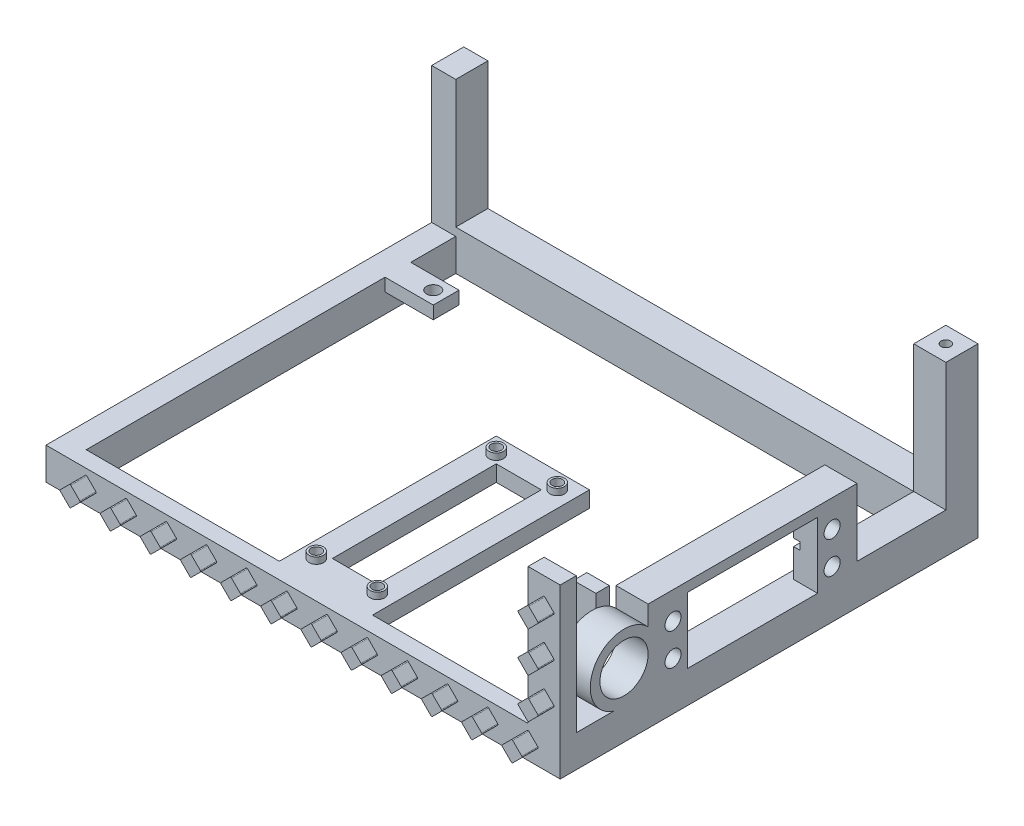
from build123d import *

# Parameters (mm, degrees)
SKETCH1_W            = 160
SKETCH1_H            = 130
BOSS_EXTRUDE1_DEPTH  = 10
BOSS_EXTRUDE2_DEPTH  = 42.3
BOSS_EXTRUDE3_DEPTH  = 5
SKETCH7_R            = 2.1
CUT_EXTRUDE2_DEPTH   = 118.958848757
CUT_EXTRUDE3_DEPTH   = 118.958848757
SKETCH11_R           = 1.5
CUT_EXTRUDE6_DEPTH   = 4
SKETCH12_W           = 142.5
SKETCH12_H           = 39.8
CUT_EXTRUDE7_DEPTH   = 160.954024645
SKETCH15_W           = 29
SKETCH15_H           = 67.5
SKETCH15_W_2         = 14
SKETCH15_H_2         = 51
SKETCH15_R           = 1.625
BOSS_EXTRUDE4_DEPTH  = 5
BOSS_EXTRUDE5_START  = 2
SKETCH15_4_R         = 2.25
SKETCH15_4_R_2       = 1.625
BOSS_EXTRUDE5_DEPTH  = 2
CUT_EXTRUDE20_DEPTH  = 5.25
SKETCH26_W           = 15
SKETCH26_H           = 8
CUT_EXTRUDE21_DEPTH  = 6
SKETCH36_W           = 55
SKETCH36_H           = 20.5
CUT_EXTRUDE27_DEPTH  = 2.5
SKETCH37_W           = 7.25
SKETCH37_H           = 2.3
CUT_EXTRUDE28_DEPTH  = 2
CUT_EXTRUDE30_DEPTH  = 10
SKETCH40_R           = 7.5
CUT_EXTRUDE32_DEPTH  = 10
SKETCH38_R           = 2.5
CUT_EXTRUDE33_DEPTH  = 10
SKETCH41_W           = 40.5
SKETCH41_H           = 20.5
CUT_EXTRUDE34_DEPTH  = 10
SKETCH48_W           = 4.2
SKETCH48_H           = 3
BOSS_EXTRUDE9_DEPTH  = 21.5
SKETCH49_W           = 7
SKETCH49_H           = 4.2
BOSS_EXTRUDE10_DEPTH = 10


with BuildPart() as part:
    # Sketch1 → Boss-Extrude1 (new body)
    with BuildSketch(Plane(origin=(0, 0, 0), x_dir=(1, 0, 0), z_dir=(0, 1, 0))):
        with Locations((-5, 5)):
            Rectangle(SKETCH1_W, SKETCH1_H)
    extrude(amount=BOSS_EXTRUDE1_DEPTH)

    # Sketch2 → Boss-Extrude2 (add)
    with BuildSketch(Plane(origin=(0, 10, 0), x_dir=(1, 0, 0), z_dir=(0, 1, 0))):
        Polygon((-85, 70), (75, 70), (75, -60), (65, -60), (65, 60), (-85, 60), align=None)
    extrude(amount=BOSS_EXTRUDE2_DEPTH)

    # Sketch6 → Boss-Extrude3 (add)
    with BuildSketch(Plane.XY.offset(60)):
        with BuildLine():
            Line((69.787867966, 40.612132034), (66.962132034, 43.437867966))
            ThreePointArc((66.962132034, 43.437867966), (66.874264069, 43.65), (66.962132034, 43.862132034))
            Line((66.962132034, 43.862132034), (69.787867966, 46.687867966))
            ThreePointArc((69.787867966, 46.687867966), (70, 46.775735931), (70.212132034, 46.687867966))
            Line((70.212132034, 46.687867966), (73.037867966, 43.862132034))
            ThreePointArc((73.037867966, 43.862132034), (73.125735931, 43.65), (73.037867966, 43.437867966))
            Line((73.037867966, 43.437867966), (70.212132034, 40.612132034))
            ThreePointArc((70.212132034, 40.612132034), (70, 40.524264069), (69.787867966, 40.612132034))
        make_face()
        with BuildLine():
            Line((-10.212132034, 8.037867966), (-13.037867966, 5.212132034))
            ThreePointArc((-13.037867966, 5.212132034), (-13.125735931, 5), (-13.037867966, 4.787867966))
            Line((-13.037867966, 4.787867966), (-10.212132034, 1.962132034))
            ThreePointArc((-10.212132034, 1.962132034), (-10, 1.874264069), (-9.787867966, 1.962132034))
            Line((-9.787867966, 1.962132034), (-6.962132034, 4.787867966))
            ThreePointArc((-6.962132034, 4.787867966), (-6.874264069, 5), (-6.962132034, 5.212132034))
            Line((-6.962132034, 5.212132034), (-9.787867966, 8.037867966))
            ThreePointArc((-9.787867966, 8.037867966), (-10, 8.125735931), (-10.212132034, 8.037867966))
        make_face()
        with BuildLine():
            Line((66.962132034, 31.362132034), (69.787867966, 34.187867966))
            ThreePointArc((69.787867966, 34.187867966), (70, 34.275735931), (70.212132034, 34.187867966))
            Line((70.212132034, 34.187867966), (73.037867966, 31.362132034))
            ThreePointArc((73.037867966, 31.362132034), (73.125735931, 31.15), (73.037867966, 30.937867966))
            Line((73.037867966, 30.937867966), (70.212132034, 28.112132034))
            ThreePointArc((70.212132034, 28.112132034), (70, 28.024264069), (69.787867966, 28.112132034))
            Line((69.787867966, 28.112132034), (66.962132034, 30.937867966))
            ThreePointArc((66.962132034, 30.937867966), (66.874264069, 31.15), (66.962132034, 31.362132034))
        make_face()
        with BuildLine():
            Line((5.537867966, 5.212132034), (2.712132034, 8.037867966))
            ThreePointArc((2.712132034, 8.037867966), (2.5, 8.125735931), (2.287867966, 8.037867966))
            Line((2.287867966, 8.037867966), (-0.537867966, 5.212132034))
            ThreePointArc((-0.537867966, 5.212132034), (-0.625735931, 5), (-0.537867966, 4.787867966))
            Line((-0.537867966, 4.787867966), (2.287867966, 1.962132034))
            ThreePointArc((2.287867966, 1.962132034), (2.5, 1.874264069), (2.712132034, 1.962132034))
            Line((2.712132034, 1.962132034), (5.537867966, 4.787867966))
            ThreePointArc((5.537867966, 4.787867966), (5.625735931, 5), (5.537867966, 5.212132034))
        make_face()
        with BuildLine():
            Line((18.037867966, 5.212132034), (15.212132034, 8.037867966))
            ThreePointArc((15.212132034, 8.037867966), (15, 8.125735931), (14.787867966, 8.037867966))
            Line((14.787867966, 8.037867966), (11.962132034, 5.212132034))
            ThreePointArc((11.962132034, 5.212132034), (11.874264069, 5), (11.962132034, 4.787867966))
            Line((11.962132034, 4.787867966), (14.787867966, 1.962132034))
            ThreePointArc((14.787867966, 1.962132034), (15, 1.874264069), (15.212132034, 1.962132034))
            Line((15.212132034, 1.962132034), (18.037867966, 4.787867966))
            ThreePointArc((18.037867966, 4.787867966), (18.125735931, 5), (18.037867966, 5.212132034))
        make_face()
        with BuildLine():
            Line((30.537867966, 5.212132034), (27.712132034, 8.037867966))
            ThreePointArc((27.712132034, 8.037867966), (27.5, 8.125735931), (27.287867966, 8.037867966))
            Line((27.287867966, 8.037867966), (24.462132034, 5.212132034))
            ThreePointArc((24.462132034, 5.212132034), (24.374264069, 5), (24.462132034, 4.787867966))
            Line((24.462132034, 4.787867966), (27.287867966, 1.962132034))
            ThreePointArc((27.287867966, 1.962132034), (27.5, 1.874264069), (27.712132034, 1.962132034))
            Line((27.712132034, 1.962132034), (30.537867966, 4.787867966))
            ThreePointArc((30.537867966, 4.787867966), (30.625735931, 5), (30.537867966, 5.212132034))
        make_face()
        with BuildLine():
            Line((43.037867966, 5.212132034), (40.212132034, 8.037867966))
            ThreePointArc((40.212132034, 8.037867966), (40, 8.125735931), (39.787867966, 8.037867966))
            Line((39.787867966, 8.037867966), (36.962132034, 5.212132034))
            ThreePointArc((36.962132034, 5.212132034), (36.874264069, 5), (36.962132034, 4.787867966))
            Line((36.962132034, 4.787867966), (39.787867966, 1.962132034))
            ThreePointArc((39.787867966, 1.962132034), (40, 1.874264069), (40.212132034, 1.962132034))
            Line((40.212132034, 1.962132034), (43.037867966, 4.787867966))
            ThreePointArc((43.037867966, 4.787867966), (43.125735931, 5), (43.037867966, 5.212132034))
        make_face()
        with BuildLine():
            Line((55.537867966, 5.212132034), (52.712132034, 8.037867966))
            ThreePointArc((52.712132034, 8.037867966), (52.5, 8.125735931), (52.287867966, 8.037867966))
            Line((52.287867966, 8.037867966), (49.462132034, 5.212132034))
            ThreePointArc((49.462132034, 5.212132034), (49.374264069, 5), (49.462132034, 4.787867966))
            Line((49.462132034, 4.787867966), (52.287867966, 1.962132034))
            ThreePointArc((52.287867966, 1.962132034), (52.5, 1.874264069), (52.712132034, 1.962132034))
            Line((52.712132034, 1.962132034), (55.537867966, 4.787867966))
            ThreePointArc((55.537867966, 4.787867966), (55.625735931, 5), (55.537867966, 5.212132034))
        make_face()
        with BuildLine():
            Line((68.037867966, 5.212132034), (65.212132034, 8.037867966))
            ThreePointArc((65.212132034, 8.037867966), (65, 8.125735931), (64.787867966, 8.037867966))
            Line((64.787867966, 8.037867966), (61.962132034, 5.212132034))
            ThreePointArc((61.962132034, 5.212132034), (61.874264069, 5), (61.962132034, 4.787867966))
            Line((61.962132034, 4.787867966), (64.787867966, 1.962132034))
            ThreePointArc((64.787867966, 1.962132034), (65, 1.874264069), (65.212132034, 1.962132034))
            Line((65.212132034, 1.962132034), (68.037867966, 4.787867966))
            ThreePointArc((68.037867966, 4.787867966), (68.125735931, 5), (68.037867966, 5.212132034))
        make_face()
        with BuildLine():
            Line((-19.462132034, 5.212132034), (-22.287867966, 8.037867966))
            ThreePointArc((-22.287867966, 8.037867966), (-22.5, 8.125735931), (-22.712132034, 8.037867966))
            Line((-22.712132034, 8.037867966), (-25.537867966, 5.212132034))
            ThreePointArc((-25.537867966, 5.212132034), (-25.625735931, 5), (-25.537867966, 4.787867966))
            Line((-25.537867966, 4.787867966), (-22.712132034, 1.962132034))
            ThreePointArc((-22.712132034, 1.962132034), (-22.5, 1.874264069), (-22.287867966, 1.962132034))
            Line((-22.287867966, 1.962132034), (-19.462132034, 4.787867966))
            ThreePointArc((-19.462132034, 4.787867966), (-19.374264069, 5), (-19.462132034, 5.212132034))
        make_face()
        with BuildLine():
            Line((-31.962132034, 5.212132034), (-34.787867966, 8.037867966))
            ThreePointArc((-34.787867966, 8.037867966), (-35, 8.125735931), (-35.212132034, 8.037867966))
            Line((-35.212132034, 8.037867966), (-38.037867966, 5.212132034))
            ThreePointArc((-38.037867966, 5.212132034), (-38.125735931, 5), (-38.037867966, 4.787867966))
            Line((-38.037867966, 4.787867966), (-35.212132034, 1.962132034))
            ThreePointArc((-35.212132034, 1.962132034), (-35, 1.874264069), (-34.787867966, 1.962132034))
            Line((-34.787867966, 1.962132034), (-31.962132034, 4.787867966))
            ThreePointArc((-31.962132034, 4.787867966), (-31.874264069, 5), (-31.962132034, 5.212132034))
        make_face()
        with BuildLine():
            Line((-44.462132034, 5.212132034), (-47.287867966, 8.037867966))
            ThreePointArc((-47.287867966, 8.037867966), (-47.5, 8.125735931), (-47.712132034, 8.037867966))
            Line((-47.712132034, 8.037867966), (-50.537867966, 5.212132034))
            ThreePointArc((-50.537867966, 5.212132034), (-50.625735931, 5), (-50.537867966, 4.787867966))
            Line((-50.537867966, 4.787867966), (-47.712132034, 1.962132034))
            ThreePointArc((-47.712132034, 1.962132034), (-47.5, 1.874264069), (-47.287867966, 1.962132034))
            Line((-47.287867966, 1.962132034), (-44.462132034, 4.787867966))
            ThreePointArc((-44.462132034, 4.787867966), (-44.374264069, 5), (-44.462132034, 5.212132034))
        make_face()
        with BuildLine():
            Line((-56.962132034, 5.212132034), (-59.787867966, 8.037867966))
            ThreePointArc((-59.787867966, 8.037867966), (-60, 8.125735931), (-60.212132034, 8.037867966))
            Line((-60.212132034, 8.037867966), (-63.037867966, 5.212132034))
            ThreePointArc((-63.037867966, 5.212132034), (-63.125735931, 5), (-63.037867966, 4.787867966))
            Line((-63.037867966, 4.787867966), (-60.212132034, 1.962132034))
            ThreePointArc((-60.212132034, 1.962132034), (-60, 1.874264069), (-59.787867966, 1.962132034))
            Line((-59.787867966, 1.962132034), (-56.962132034, 4.787867966))
            ThreePointArc((-56.962132034, 4.787867966), (-56.874264069, 5), (-56.962132034, 5.212132034))
        make_face()
        with BuildLine():
            Line((-69.462132034, 5.212132034), (-72.287867966, 8.037867966))
            ThreePointArc((-72.287867966, 8.037867966), (-72.5, 8.125735931), (-72.712132034, 8.037867966))
            Line((-72.712132034, 8.037867966), (-75.537867966, 5.212132034))
            ThreePointArc((-75.537867966, 5.212132034), (-75.625735931, 5), (-75.537867966, 4.787867966))
            Line((-75.537867966, 4.787867966), (-72.712132034, 1.962132034))
            ThreePointArc((-72.712132034, 1.962132034), (-72.5, 1.874264069), (-72.287867966, 1.962132034))
            Line((-72.287867966, 1.962132034), (-69.462132034, 4.787867966))
            ThreePointArc((-69.462132034, 4.787867966), (-69.374264069, 5), (-69.462132034, 5.212132034))
        make_face()
        with BuildLine():
            Line((69.787867966, 15.612132034), (66.962132034, 18.437867966))
            ThreePointArc((66.962132034, 18.437867966), (66.874264069, 18.65), (66.962132034, 18.862132034))
            Line((66.962132034, 18.862132034), (69.787867966, 21.687867966))
            ThreePointArc((69.787867966, 21.687867966), (70, 21.775735931), (70.212132034, 21.687867966))
            Line((70.212132034, 21.687867966), (73.037867966, 18.862132034))
            ThreePointArc((73.037867966, 18.862132034), (73.125735931, 18.65), (73.037867966, 18.437867966))
            Line((73.037867966, 18.437867966), (70.212132034, 15.612132034))
            ThreePointArc((70.212132034, 15.612132034), (70, 15.524264069), (69.787867966, 15.612132034))
        make_face()
    extrude(amount=BOSS_EXTRUDE3_DEPTH)

    # Sketch7 → Cut-Extrude2 (cut, through all)
    with BuildSketch(Plane(origin=(0, 10, 0), x_dir=(1, 0, 0), z_dir=(0, 1, 0))):
        with Locations((-66.5, 42)):
            Circle(SKETCH7_R)
    extrude(amount=-CUT_EXTRUDE2_DEPTH, mode=Mode.SUBTRACT)

    # Sketch8 → Cut-Extrude3 (cut, through all)
    with BuildSketch(Plane(origin=(0, 10, 0), x_dir=(1, 0, 0), z_dir=(0, 1, 0))):
        Polygon((-77.5, 60), (65, 60), (65, -55), (-77.5, -55), (-77.5, 38), (-62.5, 38), (-62.5, 46), (-77.5, 46), align=None)
    extrude(amount=-CUT_EXTRUDE3_DEPTH, mode=Mode.SUBTRACT)

    # Sketch11 → Cut-Extrude6 (cut)
    with BuildSketch(Plane(origin=(0, 52.3, 0), x_dir=(1, 0, 0), z_dir=(0, 1, 0))):
        with Locations((70, 65)):
            Circle(SKETCH11_R)
    extrude(amount=-CUT_EXTRUDE6_DEPTH, mode=Mode.SUBTRACT)

    # Sketch12 → Cut-Extrude7 (cut, through all)
    with BuildSketch(Plane.XY.offset(-60)):
        with Locations((-6.25, 32.4)):
            Rectangle(SKETCH12_W, SKETCH12_H)
    extrude(amount=-CUT_EXTRUDE7_DEPTH, mode=Mode.SUBTRACT)

    # Sketch15 → Boss-Extrude4 (add)
    with BuildSketch(Plane(origin=(0, 10, 0), x_dir=(1, 0, 0), z_dir=(0, 1, 0))):
        with Locations((-2.9, -21.25)):
            Rectangle(SKETCH15_W, SKETCH15_H)
        with Locations((-2.9, -20.5)):
            Rectangle(SKETCH15_W_2, SKETCH15_H_2, mode=Mode.SUBTRACT)
        with Locations((-12.4, -48.5)):
            Circle(SKETCH15_R, mode=Mode.SUBTRACT)
        with Locations((6.6, -48.5)):
            Circle(SKETCH15_R, mode=Mode.SUBTRACT)
        with Locations((-12.4, 7.5)):
            Circle(SKETCH15_R, mode=Mode.SUBTRACT)
        with Locations((6.6, 7.5)):
            Circle(SKETCH15_R, mode=Mode.SUBTRACT)
    extrude(amount=-BOSS_EXTRUDE4_DEPTH)

    # Sketch15_4 → Boss-Extrude5 (add)
    # profile 1 of 4: a face of its own
    with BuildSketch(Plane(origin=(0, 10, 0), x_dir=(1, 0, 0), z_dir=(0, 1, 0)).offset(BOSS_EXTRUDE5_START)):
        with Locations((-12.4, 7.5)):
            Circle(SKETCH15_4_R)
        with Locations((-12.4, 7.5)):
            Circle(SKETCH15_4_R_2, mode=Mode.SUBTRACT)
    # profile 2 of 4: a face of its own
    with BuildSketch(Plane(origin=(0, 10, 0), x_dir=(1, 0, 0), z_dir=(0, 1, 0)).offset(BOSS_EXTRUDE5_START)):
        with Locations((6.6, 7.5)):
            Circle(SKETCH15_4_R)
        with Locations((6.6, 7.5)):
            Circle(SKETCH15_4_R_2, mode=Mode.SUBTRACT)
    # profile 3 of 4: a face of its own
    with BuildSketch(Plane(origin=(0, 10, 0), x_dir=(1, 0, 0), z_dir=(0, 1, 0)).offset(BOSS_EXTRUDE5_START)):
        with Locations((-12.4, -48.5)):
            Circle(SKETCH15_4_R)
        with Locations((-12.4, -48.5)):
            Circle(SKETCH15_4_R_2, mode=Mode.SUBTRACT)
    # profile 4 of 4: a face of its own
    with BuildSketch(Plane(origin=(0, 10, 0), x_dir=(1, 0, 0), z_dir=(0, 1, 0)).offset(BOSS_EXTRUDE5_START)):
        with Locations((6.6, -48.5)):
            Circle(SKETCH15_4_R)
        with Locations((6.6, -48.5)):
            Circle(SKETCH15_4_R_2, mode=Mode.SUBTRACT)
    extrude(amount=-BOSS_EXTRUDE5_DEPTH)

    # Sketch25 → Cut-Extrude20 (cut)
    with BuildSketch(Plane.ZY.offset(85)):
        Polygon((0, 8.425), (-3.425, 5), (0, 1.575), (3.425, 5), align=None)
        Polygon((15.925, 5), (12.5, 8.425), (9.075, 5), (12.5, 1.575), align=None)
        Polygon((28.425, 5), (25, 8.425), (21.575, 5), (25, 1.575), align=None)
        Polygon((40.925, 5), (37.5, 8.425), (34.075, 5), (37.5, 1.575), align=None)
        Polygon((53.425, 5), (50, 8.425), (46.575, 5), (50, 1.575), align=None)
        Polygon((-9.075, 5), (-12.5, 8.425), (-15.925, 5), (-12.5, 1.575), align=None)
        Polygon((-21.575, 5), (-25, 8.425), (-28.425, 5), (-25, 1.575), align=None)
        Polygon((-34.075, 5), (-37.5, 8.425), (-40.925, 5), (-37.5, 1.575), align=None)
        Polygon((-46.575, 5), (-50, 8.425), (-53.425, 5), (-50, 1.575), align=None)
        Polygon((-59.075, 5), (-62.5, 8.425), (-65.925, 5), (-62.5, 1.575), align=None)
        Polygon((-68.425, 31.15), (-65, 34.575), (-61.575, 31.15), (-65, 27.725), align=None)
        Polygon((-65, 15.225), (-68.425, 18.65), (-65, 22.075), (-61.575, 18.65), align=None)
        Polygon((-65, 40.225), (-68.425, 43.65), (-65, 47.075), (-61.575, 43.65), align=None)
    extrude(amount=-CUT_EXTRUDE20_DEPTH, mode=Mode.SUBTRACT)

    # Sketch26 → Cut-Extrude21 (cut)
    with BuildSketch(Plane.XZ):
        with Locations((-70, -42)):
            Rectangle(SKETCH26_W, SKETCH26_H)
    extrude(amount=-CUT_EXTRUDE21_DEPTH, mode=Mode.SUBTRACT)

    # Sketch36 → Cut-Extrude27 (cut)
    with BuildSketch(Plane.ZY.offset(-65)):
        with Locations((0.15, 20.25)):
            Rectangle(SKETCH36_W, SKETCH36_H)
    extrude(amount=-CUT_EXTRUDE27_DEPTH, mode=Mode.SUBTRACT)

    # Sketch37 → Cut-Extrude28 (cut)
    with BuildSketch(Plane.ZY.offset(-67.5)):
        with Locations((-23.725, 20)):
            Rectangle(SKETCH37_W, SKETCH37_H)
    cut_extrude28 = extrude(amount=-CUT_EXTRUDE28_DEPTH, mode=Mode.SUBTRACT)

    # Sketch39 → Cut-Extrude30 (cut)
    with BuildSketch(Plane.ZY.offset(-65)):
        Polygon((-60, 52.3), (-60, 12.5), (-32.35, 12.5), (-32.35, 33.5), (55, 33.5), (55, 52.3), align=None)
    extrude(amount=-CUT_EXTRUDE30_DEPTH, mode=Mode.SUBTRACT)

    # Sketch40 → Cut-Extrude32 (cut)
    with BuildSketch(Plane.ZY.offset(-65)):
        with BuildLine():
            Line((55, 10), (55, 33.5))
            Line((55, 33.5), (32.65, 33.5))
            Line((32.65, 33.5), (32.65, 27.348469228))
            ThreePointArc((32.65, 27.348469228), (49.08652551, 25.512577601), (43.351562119, 10))
            Line((43.351562119, 10), (55, 10))
        make_face()
        with Locations((40.15, 20)):
            Circle(SKETCH40_R)
    extrude(amount=-CUT_EXTRUDE32_DEPTH, mode=Mode.SUBTRACT)

    # Sketch38 → Cut-Extrude33 (cut)
    with BuildSketch(Plane.ZY.offset(-67.5)):
        with Locations((-24.6, 25)):
            Circle(SKETCH38_R)
        with Locations((-24.6, 15)):
            Circle(SKETCH38_R)
    cut_extrude33 = extrude(amount=-CUT_EXTRUDE33_DEPTH, mode=Mode.SUBTRACT)

    # Sketch41 → Cut-Extrude34 (cut)
    with BuildSketch(Plane.ZY.offset(-67.5)):
        with Locations((0.15, 20.25)):
            Rectangle(SKETCH41_W, SKETCH41_H)
    extrude(amount=-CUT_EXTRUDE34_DEPTH, mode=Mode.SUBTRACT)

    # Mirror1: Cut-Extrude28, Cut-Extrude33 across plane
    add(cut_extrude28.mirror(Plane.XY.offset(0.15)), mode=Mode.SUBTRACT)
    add(cut_extrude33.mirror(Plane.XY.offset(0.15)), mode=Mode.SUBTRACT)

    # Sketch48 → Boss-Extrude9 (add)
    with BuildSketch(Plane.ZY.offset(-65)):
        with Locations((22.3, 8.5)):
            Rectangle(SKETCH48_W, SKETCH48_H)
    extrude(amount=BOSS_EXTRUDE9_DEPTH)

    # Sketch49 → Boss-Extrude10 (add)
    with BuildSketch(Plane(origin=(0, 10, 0), x_dir=(1, 0, 0), z_dir=(0, 1, 0))):
        with Locations((47, -22.3)):
            Rectangle(SKETCH49_W, SKETCH49_H)
    extrude(amount=BOSS_EXTRUDE10_DEPTH)


solid = part.part
